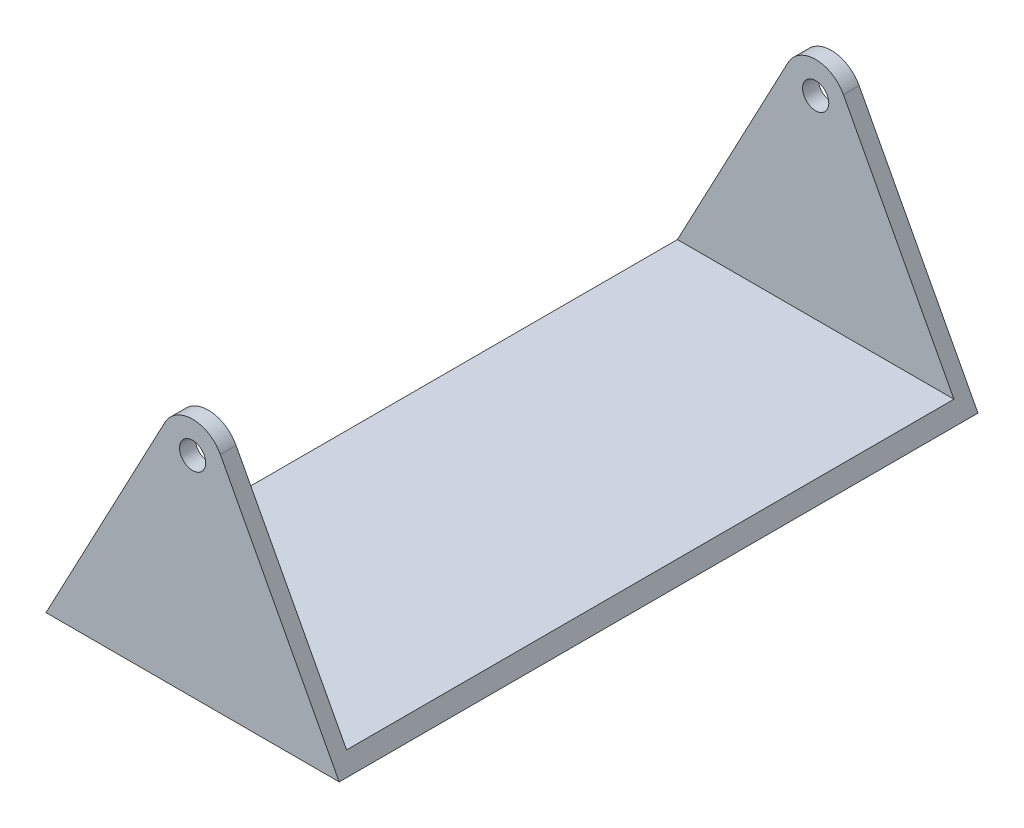
from build123d import *

# Parameters (mm, degrees)
ESQUISSE1_R                  = 2.5
BOSS_EXTRU_1_DEPTH           = 61
ESQUISSE2_W                  = 116
ESQUISSE2_H                  = 43
ENL_V_MAT_EXTRU_1_DEPTH      = 29
ENL_V_MAT_EXTRU_1_DEPTH_BACK = 29


with BuildPart() as part:
    # Esquisse1 → Boss.-Extru.1 (new body, symmetric)
    with BuildSketch(Plane.XY):
        with BuildLine():
            Line((-5.300956284, 42.810669399), (-28, 0))
            Line((-28, 0), (28, 0))
            Line((28, 0), (5.300956284, 42.810669399))
            ThreePointArc((5.300956284, 42.810669399), (0, 46), (-5.300956284, 42.810669399))
        make_face()
        with Locations((0, 40)):
            Circle(ESQUISSE1_R, mode=Mode.SUBTRACT)
    extrude(amount=BOSS_EXTRU_1_DEPTH, both=True)

    # Esquisse2 → Enlèv. mat.-Extru.1 (cut, two sides)
    with BuildSketch(Plane(origin=(0, 0, 0), x_dir=(0, 0, -1), z_dir=(1, 0, 0))) as enl_v_mat_extru_1_sk:
        with Locations((0, 24.5)):
            Rectangle(ESQUISSE2_W, ESQUISSE2_H)
    extrude(amount=ENL_V_MAT_EXTRU_1_DEPTH, mode=Mode.SUBTRACT)
    extrude(enl_v_mat_extru_1_sk.sketch, amount=-ENL_V_MAT_EXTRU_1_DEPTH_BACK, mode=Mode.SUBTRACT)


solid = part.part
